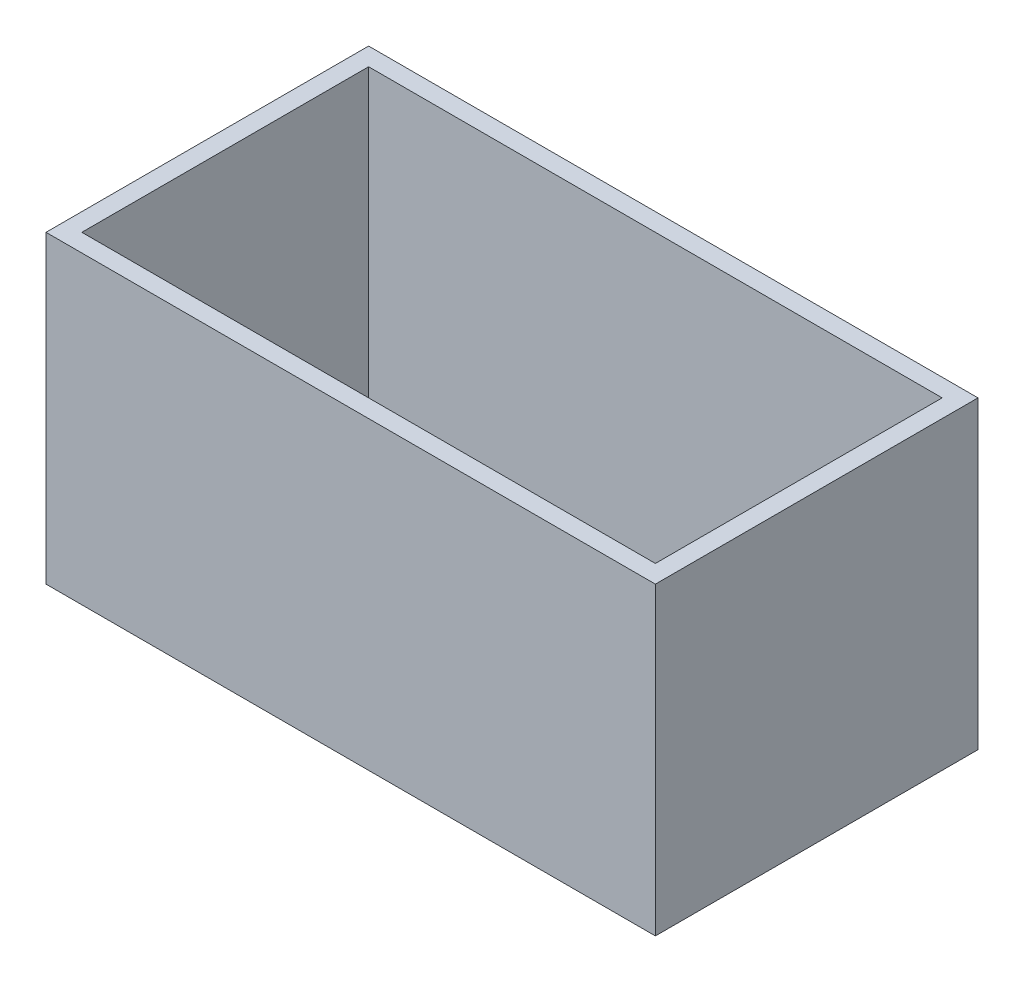
from build123d import *

# Parameters (mm, degrees)
SKETCH2_W           = 647.7
SKETCH2_H           = 342.9
BOSS_EXTRUDE1_DEPTH = 323.85
SHELL1_T            = -19.05


with BuildPart() as part:
    # Sketch2 → Boss-Extrude1 (new body)
    with BuildSketch(Plane(origin=(0, 0, 0), x_dir=(1, 0, 0), z_dir=(0, 1, 0))):
        Rectangle(SKETCH2_W, SKETCH2_H)
    extrude(amount=BOSS_EXTRUDE1_DEPTH)

    # Shell1
    shell1_openings = [part.faces().sort_by_distance(p)[0] for p in [
        (0, 323.85, 0),
    ]]
    offset(amount=SHELL1_T, openings=shell1_openings, kind=Kind.INTERSECTION)


solid = part.part
